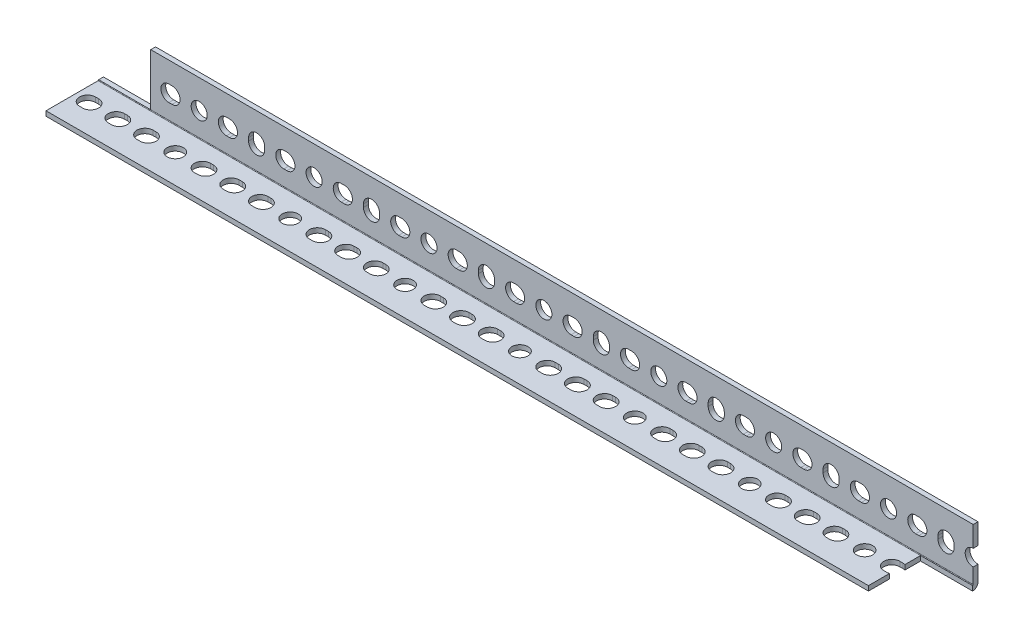
from build123d import *

# Parameters (mm, degrees)
BOSS_EXTRUDE1_DEPTH      = 1219.2
BOSS_EXTRUDE1_DEPTH_BACK = 1219.2
SKETCH5_R                = 5.334
CUT_EXTRUDE1_DEPTH       = 20.05
LPATTERN1_COUNT          = 33
LPATTERN1_PITCH          = 76.2
SKETCH6_R                = 5.334
CUT_EXTRUDE2_DEPTH       = 20.05
LPATTERN2_COUNT          = 33
LPATTERN2_PITCH          = 76.2
SKETCH7_W                = 3716.8
SKETCH7_H                = 41.656
CUT_EXTRUDE3_DEPTH       = 35.925
CUT_EXTRUDE3_DEPTH_BACK  = 4.175
SKETCH8_W                = 34.544
SKETCH8_H                = 34.544
CUT_EXTRUDE4_DEPTH       = 35.925
CUT_EXTRUDE4_DEPTH_BACK  = 4.175
SKETCH9_W                = 34.544
SKETCH9_H                = 34.544
CUT_EXTRUDE5_DEPTH       = 1
CUT_EXTRUDE5_DEPTH_BACK  = 39.1


with BuildPart() as part:
    # Sketch4 → Boss-Extrude1 (new body, two sides)
    with BuildSketch(Plane(origin=(0, 0, 0), x_dir=(0, 0, -1), z_dir=(1, 0, 0))) as boss_extrude1_sk:
        with BuildLine():
            Line((-19.05, -15.875), (15.494, -15.875))
            ThreePointArc((15.494, -15.875), (15.763407684, -15.763407684), (15.875, -15.494))
            Line((15.875, -15.494), (15.875, 19.05))
            Line((15.875, 19.05), (19.05, 19.05))
            Line((19.05, 19.05), (19.05, -15.494))
            ThreePointArc((19.05, -15.494), (18.008471714, -18.008471714), (15.494, -19.05))
            Line((15.494, -19.05), (-19.05, -19.05))
            Line((-19.05, -19.05), (-19.05, -15.875))
        make_face()
    extrude(amount=BOSS_EXTRUDE1_DEPTH)
    extrude(boss_extrude1_sk.sketch, amount=-BOSS_EXTRUDE1_DEPTH_BACK)

    # Sketch5 → Cut-Extrude1 (cut, through all)
    with BuildSketch(Plane.XY):
        with Locations((1209.675, 0)):
            Circle(SKETCH5_R)
        with BuildLine():
            Line((1189.609, 5.334), (1191.641, 5.334))
            ThreePointArc((1191.641, 5.334), (1196.975, 0), (1191.641, -5.334))
            Line((1191.641, -5.334), (1189.609, -5.334))
            ThreePointArc((1189.609, -5.334), (1184.275, 0), (1189.609, 5.334))
        make_face()
        with BuildLine():
            Line((1176.909, 1.016), (1176.909, -1.016))
            ThreePointArc((1176.909, -1.016), (1171.575, -6.35), (1166.241, -1.016))
            Line((1166.241, -1.016), (1166.241, 1.016))
            ThreePointArc((1166.241, 1.016), (1171.575, 6.35), (1176.909, 1.016))
        make_face()
        with BuildLine():
            Line((1151.509, 5.334), (1153.541, 5.334))
            ThreePointArc((1153.541, 5.334), (1158.875, 0), (1153.541, -5.334))
            Line((1153.541, -5.334), (1151.509, -5.334))
            ThreePointArc((1151.509, -5.334), (1146.175, 0), (1151.509, 5.334))
        make_face()
    cut_extrude1 = extrude(amount=-CUT_EXTRUDE1_DEPTH, mode=Mode.SUBTRACT)

    # LPattern1: Cut-Extrude1 ×33
    with Locations(*[(-i * LPATTERN1_PITCH, 0, 0) for i in range(1, LPATTERN1_COUNT)]):
        add(cut_extrude1, mode=Mode.SUBTRACT)

    # Sketch6 → Cut-Extrude2 (cut, through all)
    with BuildSketch(Plane(origin=(0, 0, 0), x_dir=(1, 0, 0), z_dir=(0, 1, 0))):
        with Locations((1209.675, 0)):
            Circle(SKETCH6_R)
        with BuildLine():
            Line((1189.609, 5.334), (1191.641, 5.334))
            ThreePointArc((1191.641, 5.334), (1196.975, 0), (1191.641, -5.334))
            Line((1191.641, -5.334), (1189.609, -5.334))
            ThreePointArc((1189.609, -5.334), (1184.275, 0), (1189.609, 5.334))
        make_face()
        with BuildLine():
            Line((1151.509, 5.334), (1153.541, 5.334))
            ThreePointArc((1153.541, 5.334), (1158.875, 0), (1153.541, -5.334))
            Line((1153.541, -5.334), (1151.509, -5.334))
            ThreePointArc((1151.509, -5.334), (1146.175, 0), (1151.509, 5.334))
        make_face()
        with BuildLine():
            Line((1170.559, 5.334), (1172.591, 5.334))
            ThreePointArc((1172.591, 5.334), (1177.925, 0), (1172.591, -5.334))
            Line((1172.591, -5.334), (1170.559, -5.334))
            ThreePointArc((1170.559, -5.334), (1165.225, 0), (1170.559, 5.334))
        make_face()
    cut_extrude2 = extrude(amount=-CUT_EXTRUDE2_DEPTH, mode=Mode.SUBTRACT)

    # LPattern2: Cut-Extrude2 ×33
    with Locations(*[(-i * LPATTERN2_PITCH, 0, 0) for i in range(1, LPATTERN2_COUNT)]):
        add(cut_extrude2, mode=Mode.SUBTRACT)

    # Sketch7 → Cut-Extrude3 (cut, two sides)
    with BuildSketch(Plane.XY.offset(-15.875)) as cut_extrude3_sk:
        with Locations((1219.2, 1.778)):
            Rectangle(SKETCH7_W, SKETCH7_H)
    extrude(amount=CUT_EXTRUDE3_DEPTH, mode=Mode.SUBTRACT)
    extrude(cut_extrude3_sk.sketch, amount=-CUT_EXTRUDE3_DEPTH_BACK, mode=Mode.SUBTRACT)

    # Sketch8 → Cut-Extrude4 (cut, two sides)
    with BuildSketch(Plane.XY.offset(-15.875)) as cut_extrude4_sk:
        with Locations((-1201.928, 1.778)):
            Rectangle(SKETCH8_W, SKETCH8_H)
    extrude(amount=CUT_EXTRUDE4_DEPTH, mode=Mode.SUBTRACT)
    extrude(cut_extrude4_sk.sketch, amount=-CUT_EXTRUDE4_DEPTH_BACK, mode=Mode.SUBTRACT)

    # Sketch9 → Cut-Extrude5 (cut, two sides)
    with BuildSketch(Plane.XZ.offset(19.05)) as cut_extrude5_sk:
        with Locations((-656.472, 1.778)):
            Rectangle(SKETCH9_W, SKETCH9_H)
    extrude(amount=CUT_EXTRUDE5_DEPTH, mode=Mode.SUBTRACT)
    extrude(cut_extrude5_sk.sketch, amount=-CUT_EXTRUDE5_DEPTH_BACK, mode=Mode.SUBTRACT)


solid = part.part
